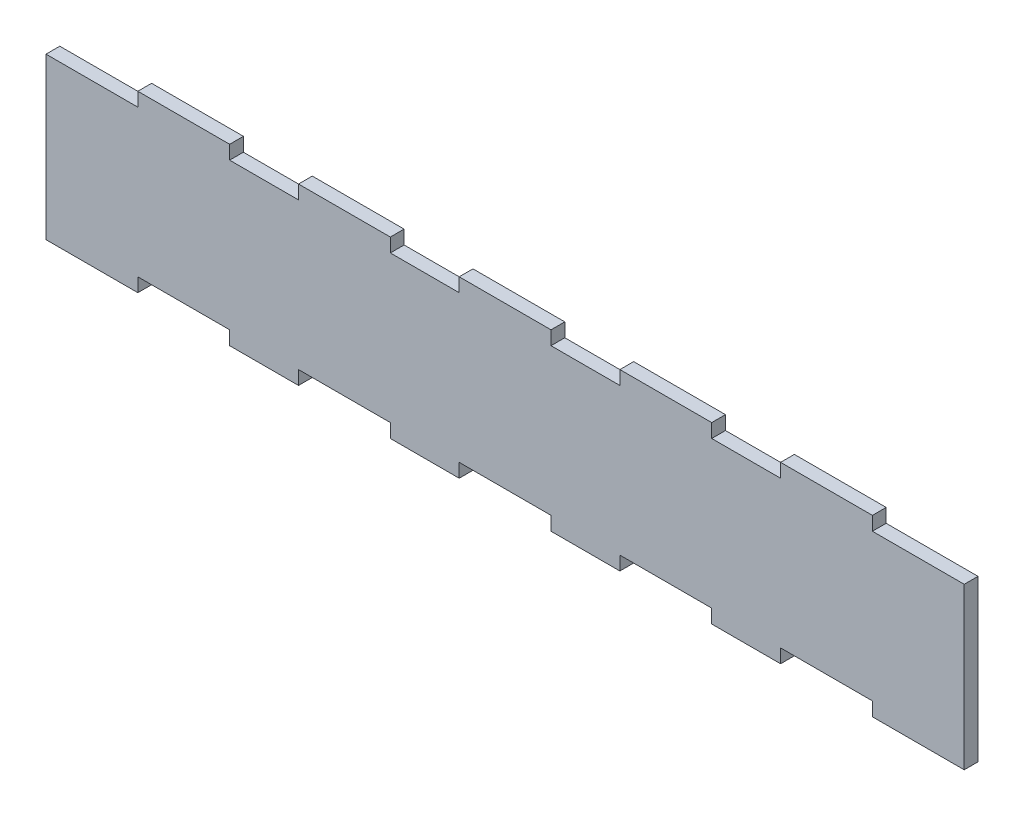
from build123d import *

# Parameters (mm, degrees)
BOSS_EXTRUDE1_DEPTH = 3


with BuildPart() as part:
    # Sketch1 → Boss-Extrude1 (new body)
    with BuildSketch(Plane(origin=(0, 0, 0), x_dir=(1, 0, 0), z_dir=(0, 0, -1))):
        Polygon((40, 0), (55, 0), (55, -3), (75, -3), (75, 0), (90, 0), (90, -3), (110, -3), (110, 0), (125, 0), (125, -3), (145, -3), (145, 0), (160, 0), (160, -3), (180, -3), (180, 0), (200, 0), (200, 35), (180, 35), (180, 32), (160, 32), (160, 35), (145, 35), (145, 32), (125, 32), (125, 35), (110, 35), (110, 32), (90, 32), (90, 35), (75, 35), (75, 32), (55, 32), (55, 35), (40, 35), (40, 32), (20, 32), (20, 35), (0, 35), (0, 0), (20, 0), (20, -3), (40, -3), align=None)
    extrude(amount=BOSS_EXTRUDE1_DEPTH)


solid = part.part
